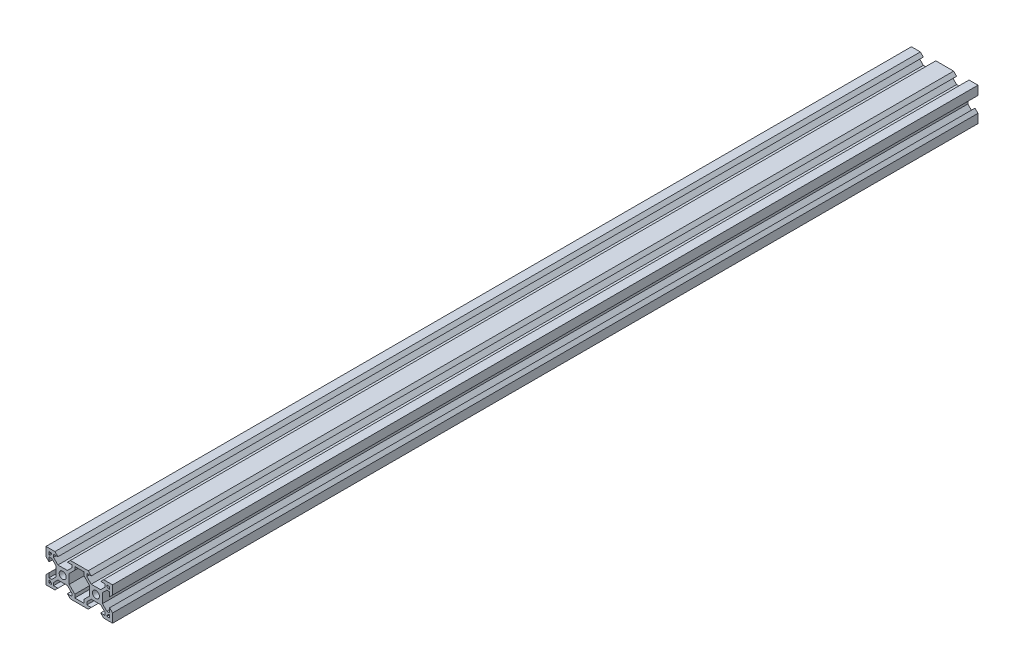
from build123d import *

# Parameters (mm, degrees)
SKETCH1_R           = 2.1
BOSS_EXTRUDE1_DEPTH = 520


with BuildPart() as part:
    # Sketch1 → Boss-Extrude1 (new body)
    with BuildSketch(Plane.XY):
        Polygon((0, 0), (0, 5.36), (1.8, 7.16), (1.8, 4.500660172), (3.44, 4.500660172), (6.099339828, 7.16), (6.099339828, 12.84), (3.44, 15.499339828), (1.8, 15.499339828), (1.8, 12.84), (0, 14.64), (0, 20), (5.36, 20), (7.16, 18.2), (4.500660172, 18.2), (4.500660172, 16.56), (7.16, 13.900660172), (12.84, 13.900660172), (15.499339828, 16.56), (15.499339828, 18.2), (12.84, 18.2), (14.64, 20), (20, 20), (25.36, 20), (27.16, 18.2), (24.500939946, 18.2), (24.50125838, 16.559689577), (27.161114417, 13.900866058), (32.84111431, 13.901968719), (35.499937829, 16.561824756), (35.49961981, 18.2), (32.84, 18.2), (34.64, 20), (39.999930631, 20), (40.000970647, 14.642698508), (38.201320116, 12.842349107), (38.200803857, 15.501688885), (36.560803888, 15.501370511), (33.901980368, 12.841514474), (33.903083029, 7.161514581), (36.562939066, 4.502691062), (38.202939036, 4.503009436), (38.202422777, 7.162349214), (40.002772178, 5.362698683), (40.003813241, 0), (34.64, 0), (32.84, 1.8), (35.502803549, 1.8), (35.502484821, 3.441825004), (32.842628784, 6.100648523), (27.162628891, 6.099545862), (24.503805372, 3.439689825), (24.504123686, 1.8), (27.16, 1.8), (25.36, 0), (20, 0), (14.64, 0), (12.84, 1.8), (15.499339828, 1.8), (15.499339828, 3.44), (12.84, 6.099339828), (7.16, 6.099339828), (4.500660172, 3.44), (4.500660172, 1.8), (7.16, 1.8), (5.36, 0), align=None)
        with Locations((10, 10)):
            Circle(SKETCH1_R, mode=Mode.SUBTRACT)
        with Locations((30, 10)):
            Circle(SKETCH1_R, mode=Mode.SUBTRACT)
        Polygon((17.300660172, 3.76), (17.300660172, 1.8), (22.700660172, 1.8), (22.700660172, 3.76), (26.100660172, 7.16), (26.100660172, 12.84), (22.699339828, 16.24), (22.699339828, 18.2), (17.300660172, 18.2), (17.300660172, 16.24), (13.900660172, 12.84), (13.900660172, 7.16), align=None, mode=Mode.SUBTRACT)
        Polygon((1.8, 18.2), (3.430660172, 18.2), (3.430660172, 17.63), (2.37, 16.569339828), (1.8, 16.569339828), align=None, mode=Mode.SUBTRACT)
        Polygon((1.8, 3.430660172), (1.8, 1.8), (3.430660172, 1.8), (3.430660172, 2.37), (2.37, 3.430660172), align=None, mode=Mode.SUBTRACT)
        Polygon((38.2, 1.8), (36.569339828, 1.8), (36.569339828, 2.37), (37.63, 3.430660172), (38.2, 3.430660172), align=None, mode=Mode.SUBTRACT)
        Polygon((38.2, 16.569339828), (38.2, 18.2), (36.569339828, 18.2), (36.569339828, 17.63), (37.63, 16.569339828), align=None, mode=Mode.SUBTRACT)
    extrude(amount=-BOSS_EXTRUDE1_DEPTH)


solid = part.part
